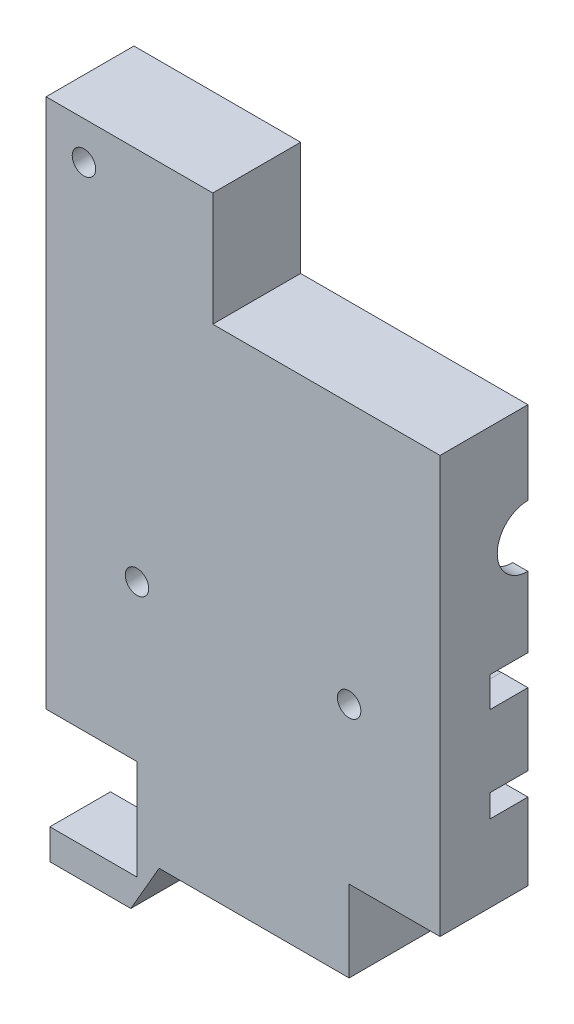
from build123d import *

# Parameters (mm, degrees)
CROQUIS1_W              = 52
CROQUIS1_H              = 90
SALIENTE_EXTRUIR1_DEPTH = 11.6
CORTAR_EXTRUIR1_DEPTH   = 48
CORTAR_EXTRUIR2_DEPTH   = 24
CORTAR_EXTRUIR3_DEPTH   = 53
CORTAR_EXTRUIR4_DEPTH   = 53
CORTAR_EXTRUIR7_DEPTH   = 8
CROQUIS7_R              = 4
SALIENTE_EXTRUIR2_DEPTH = 12
CROQUIS8_W              = 2
CROQUIS8_H              = 4
CORTAR_EXTRUIR8_DEPTH   = 5
SALIENTE_EXTRUIR4_DEPTH = 8
CROQUIS10_R             = 1.55
CORTAR_EXTRUIR9_DEPTH   = 16.6
CROQUIS11_R             = 2.8
CROQUIS11_R_2           = 1.55
CORTAR_EXTRUIR10_DEPTH  = 3
CROQUIS12_W             = 5
CROQUIS12_H             = 3
CORTAR_EXTRUIR11_DEPTH  = 53
CROQUIS13_W             = 30
CROQUIS13_H             = 15
CORTAR_EXTRUIR12_DEPTH  = 12
CROQUIS14_R             = 1.55
CORTAR_EXTRUIR13_DEPTH  = 12
CROQUIS14_3_R           = 2.8
CROQUIS14_3_R_2         = 1.55
CORTAR_EXTRUIR14_DEPTH  = 3
CROQUIS15_W             = 48
CROQUIS15_H             = 1.2
SALIENTE_EXTRUIR5_DEPTH = 8
CROQUIS16_W             = 12
CROQUIS16_H             = 20
CORTAR_EXTRUIR15_DEPTH  = 12.6
CROQUIS17_W             = 12
CROQUIS17_H             = 20
CORTAR_EXTRUIR16_DEPTH  = 12.6
CROQUIS18_W             = 11.5
CROQUIS18_H             = 4
SALIENTE_EXTRUIR6_DEPTH = 8
CROQUIS19_R             = 4
SALIENTE_EXTRUIR7_DEPTH = 12
CROQUIS20_R             = 1.55
CORTAR_EXTRUIR17_DEPTH  = 16.6
CROQUIS20_3_R           = 2.8
CROQUIS20_3_R_2         = 1.55
CORTAR_EXTRUIR18_DEPTH  = 3
CROQUIS21_W             = 28
CROQUIS21_H             = 2.8
CORTAR_EXTRUIR19_DEPTH  = 16.6
CORTAR_EXTRUIR20_DEPTH  = 16.6


with BuildPart() as part:
    # Croquis1 → Saliente-Extruir1 (new body)
    with BuildSketch(Plane.XY):
        with Locations((26, 45)):
            Rectangle(CROQUIS1_W, CROQUIS1_H)
    extrude(amount=SALIENTE_EXTRUIR1_DEPTH)

    # Croquis2 → Cortar-Extruir1 (cut)
    with BuildSketch(Plane(origin=(50, 0, 0), x_dir=(0, 0, -1), z_dir=(1, 0, 0))):
        with BuildLine():
            Line((0, 52.45), (0, 67.55))
            ThreePointArc((0, 67.55), (-7.55, 60), (0, 52.45))
        make_face()
    extrude(amount=-CORTAR_EXTRUIR1_DEPTH, mode=Mode.SUBTRACT)

    # Croquis3 → Cortar-Extruir2 (cut)
    with BuildSketch(Plane(origin=(38, 0, 0), x_dir=(0, 0, -1), z_dir=(1, 0, 0))):
        with BuildLine():
            Line((0, 7.45), (0, 22.55))
            ThreePointArc((0, 22.55), (-7.55, 15), (0, 7.45))
        make_face()
    extrude(amount=-CORTAR_EXTRUIR2_DEPTH, mode=Mode.SUBTRACT)

    # Croquis4 → Cortar-Extruir3 (cut, through all)
    with BuildSketch(Plane(origin=(52, 0, 0), x_dir=(0, 0, -1), z_dir=(1, 0, 0))):
        with BuildLine():
            ThreePointArc((0, 64.05), (-4.05, 60), (0, 55.95))
            Line((0, 55.95), (0, 64.05))
        make_face()
        with BuildLine():
            Line((0, 64.05), (0, 55.95))
            ThreePointArc((0, 55.95), (2.863782464, 57.136217536), (4.05, 60))
            ThreePointArc((4.05, 60), (2.863782464, 62.863782464), (0, 64.05))
        make_face()
    extrude(amount=-CORTAR_EXTRUIR3_DEPTH, mode=Mode.SUBTRACT)

    # Croquis5 → Cortar-Extruir4 (cut, through all)
    with BuildSketch(Plane(origin=(52, 0, 0), x_dir=(0, 0, -1), z_dir=(1, 0, 0))):
        with BuildLine():
            ThreePointArc((0, 19.05), (-4.05, 15), (0, 10.95))
            Line((0, 10.95), (0, 19.05))
        make_face()
        with BuildLine():
            Line((0, 19.05), (0, 10.95))
            ThreePointArc((0, 10.95), (2.863782464, 12.136217536), (4.05, 15))
            ThreePointArc((4.05, 15), (2.863782464, 17.863782464), (0, 19.05))
        make_face()
    extrude(amount=-CORTAR_EXTRUIR4_DEPTH, mode=Mode.SUBTRACT)

    # Croquis6 → Cortar-Extruir7 (cut)
    with BuildSketch(Plane(origin=(0, 0, 0), x_dir=(-1, 0, 0), z_dir=(0, 0, -1))):
        Polygon((-2, 49.95), (-2, 21.55), (-11.5, 21.55), (-11.5, 25.05), (-40.5, 25.05), (-40.5, 21.55), (-50, 21.55), (-50, 49.95), align=None)
    extrude(amount=-CORTAR_EXTRUIR7_DEPTH, mode=Mode.SUBTRACT)

    # Croquis7 → Saliente-Extruir2 (add)
    with BuildSketch(Plane(origin=(0, 0, 8), x_dir=(-1, 0, 0), z_dir=(0, 0, -1))):
        with Locations((-40, 40.55)):
            Circle(CROQUIS7_R)
    extrude(amount=SALIENTE_EXTRUIR2_DEPTH)

    # Croquis8 → Cortar-Extruir8 (cut)
    with BuildSketch(Plane(origin=(0, 0, 0), x_dir=(-1, 0, 0), z_dir=(0, 0, -1))):
        with Locations((-51, 44.65)):
            Rectangle(CROQUIS8_W, CROQUIS8_H)
    extrude(amount=-CORTAR_EXTRUIR8_DEPTH, mode=Mode.SUBTRACT)

    # Croquis9 → Saliente-Extruir4 (add)
    with BuildSketch(Plane(origin=(0, 0, 0), x_dir=(-1, 0, 0), z_dir=(0, 0, -1))):
        with BuildLine():
            Line((-52, 42.65), (-48.495265185, 42.65))
            ThreePointArc((-48.495265185, 42.65), (-47.081051623, 42.064213562), (-46.495265185, 40.65))
            Line((-46.495265185, 40.65), (-46.495265185, 37.65))
            Line((-46.495265185, 37.65), (-52, 37.65))
            Line((-52, 37.65), (-52, 42.65))
        make_face()
    extrude(amount=-SALIENTE_EXTRUIR4_DEPTH)

    # Croquis10 → Cortar-Extruir9 (cut, through all)
    with BuildSketch(Plane(origin=(0, 0, -4), x_dir=(-1, 0, 0), z_dir=(0, 0, -1))):
        with Locations((-40, 40.55)):
            Circle(CROQUIS10_R)
    extrude(amount=-CORTAR_EXTRUIR9_DEPTH, mode=Mode.SUBTRACT)

    # Croquis11 → Cortar-Extruir10 (cut)
    with BuildSketch(Plane(origin=(0, 0, -4), x_dir=(-1, 0, 0), z_dir=(0, 0, -1))):
        with Locations((-40, 40.55)):
            Circle(CROQUIS11_R)
        with Locations((-40, 40.55)):
            Circle(CROQUIS11_R_2, mode=Mode.SUBTRACT)
    extrude(amount=-CORTAR_EXTRUIR10_DEPTH, mode=Mode.SUBTRACT)

    # Croquis12 → Cortar-Extruir11 (cut, through all)
    with BuildSketch(Plane(origin=(52, 0, 0), x_dir=(0, 0, -1), z_dir=(1, 0, 0))):
        with Locations((-2.5, 31.65)):
            Rectangle(CROQUIS12_W, CROQUIS12_H)
    extrude(amount=-CORTAR_EXTRUIR11_DEPTH, mode=Mode.SUBTRACT)

    # Croquis13 → Cortar-Extruir12 (cut)
    with BuildSketch(Plane(origin=(0, 0, 0), x_dir=(-1, 0, 0), z_dir=(0, 0, -1))):
        with Locations((-37, 82.5)):
            Rectangle(CROQUIS13_W, CROQUIS13_H)
    extrude(amount=-CORTAR_EXTRUIR12_DEPTH, mode=Mode.SUBTRACT)

    # Croquis14 → Cortar-Extruir13 (cut)
    with BuildSketch(Plane(origin=(0, 0, 0), x_dir=(-1, 0, 0), z_dir=(0, 0, -1))):
        with Locations((-5, 85)):
            Circle(CROQUIS14_R)
    extrude(amount=-CORTAR_EXTRUIR13_DEPTH, mode=Mode.SUBTRACT)

    # Croquis14_3 → Cortar-Extruir14 (cut)
    with BuildSketch(Plane(origin=(0, 0, 0), x_dir=(-1, 0, 0), z_dir=(0, 0, -1))):
        with Locations((-5, 85)):
            Circle(CROQUIS14_3_R)
        with Locations((-5, 85)):
            Circle(CROQUIS14_3_R_2, mode=Mode.SUBTRACT)
    extrude(amount=-CORTAR_EXTRUIR14_DEPTH, mode=Mode.SUBTRACT)

    # Croquis15 → Saliente-Extruir5 (add)
    with BuildSketch(Plane(origin=(0, 0, 8), x_dir=(-1, 0, 0), z_dir=(0, 0, -1))):
        with Locations((-26, 29.55)):
            Rectangle(CROQUIS15_W, CROQUIS15_H)
    extrude(amount=SALIENTE_EXTRUIR5_DEPTH)

    # Croquis16 → Cortar-Extruir15 (cut, through all)
    with BuildSketch(Plane(origin=(0, 0, 0), x_dir=(-1, 0, 0), z_dir=(0, 0, -1))):
        with Locations((-46, 10)):
            Rectangle(CROQUIS16_W, CROQUIS16_H)
    extrude(amount=-CORTAR_EXTRUIR15_DEPTH, mode=Mode.SUBTRACT)

    # Croquis17 → Cortar-Extruir16 (cut, through all)
    with BuildSketch(Plane(origin=(0, 0, 0), x_dir=(-1, 0, 0), z_dir=(0, 0, -1))):
        with Locations((-6, 10)):
            Rectangle(CROQUIS17_W, CROQUIS17_H)
    extrude(amount=-CORTAR_EXTRUIR16_DEPTH, mode=Mode.SUBTRACT)

    # Croquis18 → Saliente-Extruir6 (add)
    with BuildSketch(Plane.XY.offset(11.6)):
        with Locations((6.25, 4.8)):
            Rectangle(CROQUIS18_W, CROQUIS18_H)
    extrude(amount=-SALIENTE_EXTRUIR6_DEPTH)

    # Croquis19 → Saliente-Extruir7 (add)
    with BuildSketch(Plane(origin=(0, 0, 8), x_dir=(-1, 0, 0), z_dir=(0, 0, -1))):
        with Locations((-12, 40.55)):
            Circle(CROQUIS19_R)
    extrude(amount=SALIENTE_EXTRUIR7_DEPTH)

    # Croquis20 → Cortar-Extruir17 (cut, through all)
    with BuildSketch(Plane(origin=(0, 0, -4), x_dir=(-1, 0, 0), z_dir=(0, 0, -1))):
        with Locations((-12, 40.55)):
            Circle(CROQUIS20_R)
    extrude(amount=-CORTAR_EXTRUIR17_DEPTH, mode=Mode.SUBTRACT)

    # Croquis20_3 → Cortar-Extruir18 (cut)
    with BuildSketch(Plane(origin=(0, 0, -4), x_dir=(-1, 0, 0), z_dir=(0, 0, -1))):
        with Locations((-12, 40.55)):
            Circle(CROQUIS20_3_R)
        with Locations((-12, 40.55)):
            Circle(CROQUIS20_3_R_2, mode=Mode.SUBTRACT)
    extrude(amount=-CORTAR_EXTRUIR18_DEPTH, mode=Mode.SUBTRACT)

    # Croquis21 → Cortar-Extruir19 (cut, through all)
    with BuildSketch(Plane.XY.offset(11.6)):
        with Locations((26, 1.4)):
            Rectangle(CROQUIS21_W, CROQUIS21_H)
    extrude(amount=-CORTAR_EXTRUIR19_DEPTH, mode=Mode.SUBTRACT)

    # Croquis22 → Cortar-Extruir20 (cut, through all)
    with BuildSketch(Plane.XY.offset(11.6)):
        Polygon((11.184549083, 2.8), (40, 2.8), (40, 9.264101615), (14.916599891, 9.264101615), align=None)
    extrude(amount=-CORTAR_EXTRUIR20_DEPTH, mode=Mode.SUBTRACT)


solid = part.part
